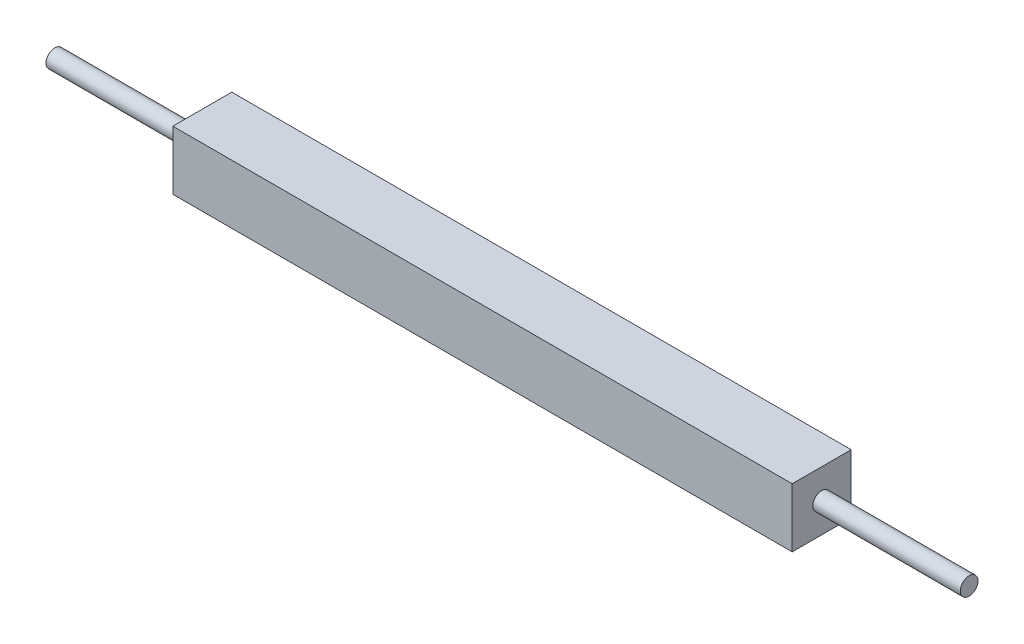
from build123d import *

# Parameters (mm, degrees)
SKETCH1_W           = 210
SKETCH1_H           = 40
BOSS_EXTRUDE1_DEPTH = 40
SKETCH2_R           = 6
BOSS_EXTRUDE2_DEPTH = 100


with BuildPart() as part:
    # Sketch1 → Boss-Extrude1 (new body)
    with BuildSketch(Plane.XY):
        with Locations((-105, 0)):
            Rectangle(SKETCH1_W, SKETCH1_H)
    extrude(amount=BOSS_EXTRUDE1_DEPTH)

    # Sketch2 → Boss-Extrude2 (add)
    with BuildSketch(Plane.ZY.offset(210)):
        with Locations((20, 0)):
            Circle(SKETCH2_R)
    extrude(amount=BOSS_EXTRUDE2_DEPTH)

    # Mirror1: part across plane


with BuildPart() as part_1:
    add(part.part)
    add(part.part.mirror(Plane(origin=(0, 20, 40), x_dir=(0, 0, 1), z_dir=(-1, 0, 0))))


solid = part_1.part
